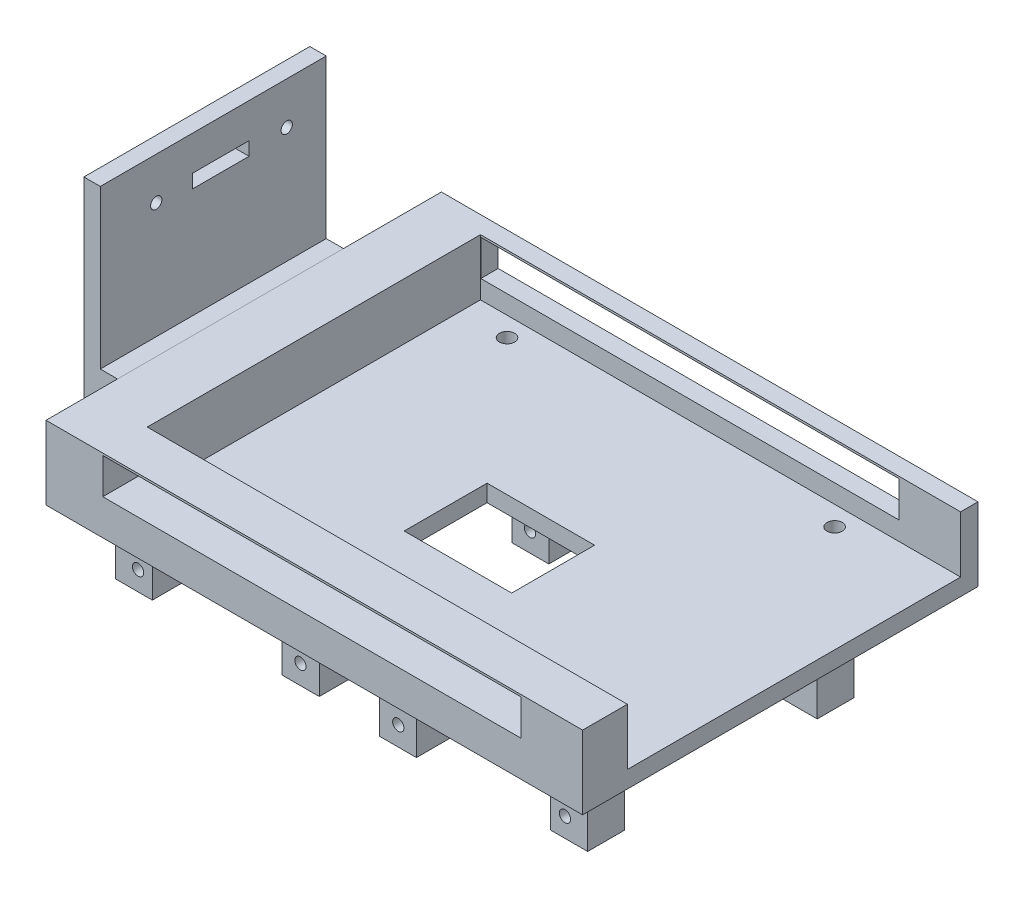
from build123d import *

# Parameters (mm, degrees)
SKETCH_1_W           = 95
SKETCH_1_H           = 70
SKETCH_1_R           = 1.35
SKETCH_1_W_2         = 19.026786566
SKETCH_1_H_2         = 14.673074928
EXTRUDE_1_DEPTH      = 13
SKETCH_3_W           = 85
SKETCH_3_H           = 59
CUT_EXTRUDE_1_DEPTH  = 10
SKETCH_4_W           = 6.551363844
SKETCH_4_H           = 6.551363844
EXTRUDE_2_DEPTH      = 12
SKETCH_7_W           = 6.551363844
SKETCH_7_H           = 6.551363844
EXTRUDE_3_DEPTH      = 12
SKETCH_9_R           = 1
CUT_EXTRUDE_4_DEPTH  = 63
SKETCH_5_R           = 1
CUT_EXTRUDE_5_DEPTH  = 56
SKETCH_12_W          = 6.551363844
SKETCH_12_H          = 6.551363844
EXTRUDE_4_DEPTH      = 12
SKETCH_13_R          = 1
CUT_EXTRUDE_6_DEPTH  = 9
SKETCH_15_R          = 1
CUT_EXTRUDE_7_DEPTH  = 51
SKETCH_17_W          = 6.551363844
SKETCH_17_H          = 6.551363844
EXTRUDE_5_DEPTH      = 12
SKETCH_18_R          = 1
CUT_EXTRUDE_8_DEPTH  = 12
SKETCH_19_R          = 1
CUT_EXTRUDE_9_DEPTH  = 12
SKETCH_20_W          = 40
SKETCH_20_H          = 7.86503053
EXTRUDE_6_DEPTH      = 6
SKETCH_21_W          = 2.903775518
SKETCH_21_H          = 40
EXTRUDE_7_DEPTH      = 28
SKETCH_22_W          = 74
SKETCH_22_H          = 6.331212291
CUT_EXTRUDE_10_DEPTH = 78
SKETCH_23_W          = 10
SKETCH_23_H          = 2.4
CUT_EXTRUDE_13_DEPTH = 10
SKETCH_25_R          = 1
CUT_EXTRUDE_14_DEPTH = 10


with BuildPart() as part:
    # 草图1 → 凸台-拉伸1 (new body)
    with BuildSketch(Plane(origin=(0, 0, 0), x_dir=(1, 0, 0), z_dir=(0, 1, 0))):
        with Locations((21.0257099, -17.142747506)):
            Rectangle(SKETCH_1_W, SKETCH_1_H)
        with Locations((49.670533911, 11.329362359)):
            Circle(SKETCH_1_R, mode=Mode.SUBTRACT)
        with Locations((49.670533911, -37.670637641)):
            Circle(SKETCH_1_R, mode=Mode.SUBTRACT)
        with Locations((-8.329466089, -37.670637641)):
            Circle(SKETCH_1_R, mode=Mode.SUBTRACT)
        with Locations((-8.329466089, 11.329362359)):
            Circle(SKETCH_1_R, mode=Mode.SUBTRACT)
        with Locations((21.72534394, -20.076013692)):
            Rectangle(SKETCH_1_W_2, SKETCH_1_H_2, mode=Mode.SUBTRACT)
    extrude(amount=EXTRUDE_1_DEPTH)

    # 草图3 → 切除-拉伸1 (cut)
    with BuildSketch(Plane(origin=(0, 13, 0), x_dir=(1, 0, 0), z_dir=(0, 1, 0))):
        with Locations((26.0257099, -14.722914633)):
            Rectangle(SKETCH_3_W, SKETCH_3_H)
    extrude(amount=-CUT_EXTRUDE_1_DEPTH, mode=Mode.SUBTRACT)

    # 草图4 → 凸台-拉伸2 (add)
    with BuildSketch(Plane.XZ):
        with Locations((-17.262018052, 1.397045451)):
            Rectangle(SKETCH_4_W, SKETCH_4_H)
        with Locations((-17.755298179, 42.036450596)):
            Rectangle(SKETCH_4_W, SKETCH_4_H)
        with Locations((59.313437853, 1.397045451)):
            Rectangle(SKETCH_4_W, SKETCH_4_H)
        with Locations((59.313437853, 42.036450596)):
            Rectangle(SKETCH_4_W, SKETCH_4_H)
    extrude(amount=EXTRUDE_2_DEPTH)

    # 草图7 → 凸台-拉伸3 (add)
    with BuildSketch(Plane.XZ):
        with Locations((29.762074009, 2.155967477)):
            Rectangle(SKETCH_7_W, SKETCH_7_H)
    extrude(amount=EXTRUDE_3_DEPTH)

    # 草图9 → 切除-拉伸4 (cut)
    with BuildSketch(Plane(origin=(0, 0, -1.119714445), x_dir=(-1, 0, 0), z_dir=(0, 0, -1))):
        with Locations((-29.819487591, -8.583293227)):
            Circle(SKETCH_9_R)
    extrude(amount=-CUT_EXTRUDE_4_DEPTH, mode=Mode.SUBTRACT)

    # 草图5 → 切除-拉伸5 (cut)
    with BuildSketch(Plane(origin=(0, 0, -1.878636471), x_dir=(-1, 0, 0), z_dir=(0, 0, -1))):
        with Locations((-58.566110561, -8.583293227)):
            Circle(SKETCH_5_R)
    extrude(amount=-CUT_EXTRUDE_5_DEPTH, mode=Mode.SUBTRACT)

    # 草图12 → 凸台-拉伸4 (add)
    with BuildSketch(Plane(origin=(0, 0, 0), x_dir=(-1, 0, 0), z_dir=(0, -1, 0))):
        with Locations((-29.762074009, -42.795372621)):
            Rectangle(SKETCH_12_W, SKETCH_12_H)
    extrude(amount=EXTRUDE_4_DEPTH)

    # 草图13 → 切除-拉伸6 (cut)
    with BuildSketch(Plane.XY.offset(46.071054543)):
        with Locations((29.819487591, -8.583293227)):
            Circle(SKETCH_13_R)
    extrude(amount=-CUT_EXTRUDE_6_DEPTH, mode=Mode.SUBTRACT)

    # 草图15 → 切除-拉伸7 (cut)
    with BuildSketch(Plane.XY.offset(45.312132518)):
        with Locations((-17.007970887, -8.583602404)):
            Circle(SKETCH_15_R)
    extrude(amount=-CUT_EXTRUDE_7_DEPTH, mode=Mode.SUBTRACT)

    # 草图17 → 凸台-拉伸5 (add)
    with BuildSketch(Plane(origin=(0, 0, 0), x_dir=(-1, 0, 0), z_dir=(0, -1, 0))):
        with Locations((-11.796065665, -42.036450596)):
            Rectangle(SKETCH_17_W, SKETCH_17_H)
        with Locations((-11.796065665, -1.397045451)):
            Rectangle(SKETCH_17_W, SKETCH_17_H)
    extrude(amount=EXTRUDE_5_DEPTH)

    # 草图18 → 切除-拉伸8 (cut)
    with BuildSketch(Plane.XY.offset(45.312132518)):
        with Locations((11.738652082, -8.583602404)):
            Circle(SKETCH_18_R)
    extrude(amount=-CUT_EXTRUDE_8_DEPTH, mode=Mode.SUBTRACT)

    # 草图19 → 切除-拉伸9 (cut)
    with BuildSketch(Plane(origin=(0, 0, -1.878636471), x_dir=(-1, 0, 0), z_dir=(0, 0, -1))):
        with Locations((-11.738652082, -8.583602404)):
            Circle(SKETCH_19_R)
    extrude(amount=-CUT_EXTRUDE_9_DEPTH, mode=Mode.SUBTRACT)

    # 草图20 → 凸台-拉伸6 (add)
    with BuildSketch(Plane.ZY.offset(26.4742901)):
        with Locations((19.434170465, 9.018379662)):
            Rectangle(SKETCH_20_W, SKETCH_20_H)
    extrude(amount=EXTRUDE_6_DEPTH)

    # 草图21 → 凸台-拉伸7 (add)
    with BuildSketch(Plane(origin=(0, 12.950894927, 0), x_dir=(1, 0, 0), z_dir=(0, 1, 0))):
        with Locations((-31.022402341, -19.434170465)):
            Rectangle(SKETCH_21_W, SKETCH_21_H)
    extrude(amount=EXTRUDE_7_DEPTH)

    # 草图22 → 切除-拉伸10 (cut)
    with BuildSketch(Plane(origin=(0, 0, -17.857252494), x_dir=(-1, 0, 0), z_dir=(0, 0, -1))):
        with Locations((-20.578648713, 9.467151169)):
            Rectangle(SKETCH_22_W, SKETCH_22_H)
    extrude(amount=-CUT_EXTRUDE_10_DEPTH, mode=Mode.SUBTRACT)

    # 草图23 → 切除-拉伸13 (cut)
    with BuildSketch(Plane.ZY.offset(32.4742901)):
        with Locations((18.096879679, 33.602818556)):
            Rectangle(SKETCH_23_W, SKETCH_23_H)
    extrude(amount=-CUT_EXTRUDE_13_DEPTH, mode=Mode.SUBTRACT)

    # 草图25 → 切除-拉伸14 (cut)
    with BuildSketch(Plane.ZY.offset(32.4742901)):
        with Locations((6.428608959, 33.489118381)):
            Circle(SKETCH_25_R)
        with Locations((29.528608959, 33.489118381)):
            Circle(SKETCH_25_R)
    extrude(amount=-CUT_EXTRUDE_14_DEPTH, mode=Mode.SUBTRACT)


solid = part.part
